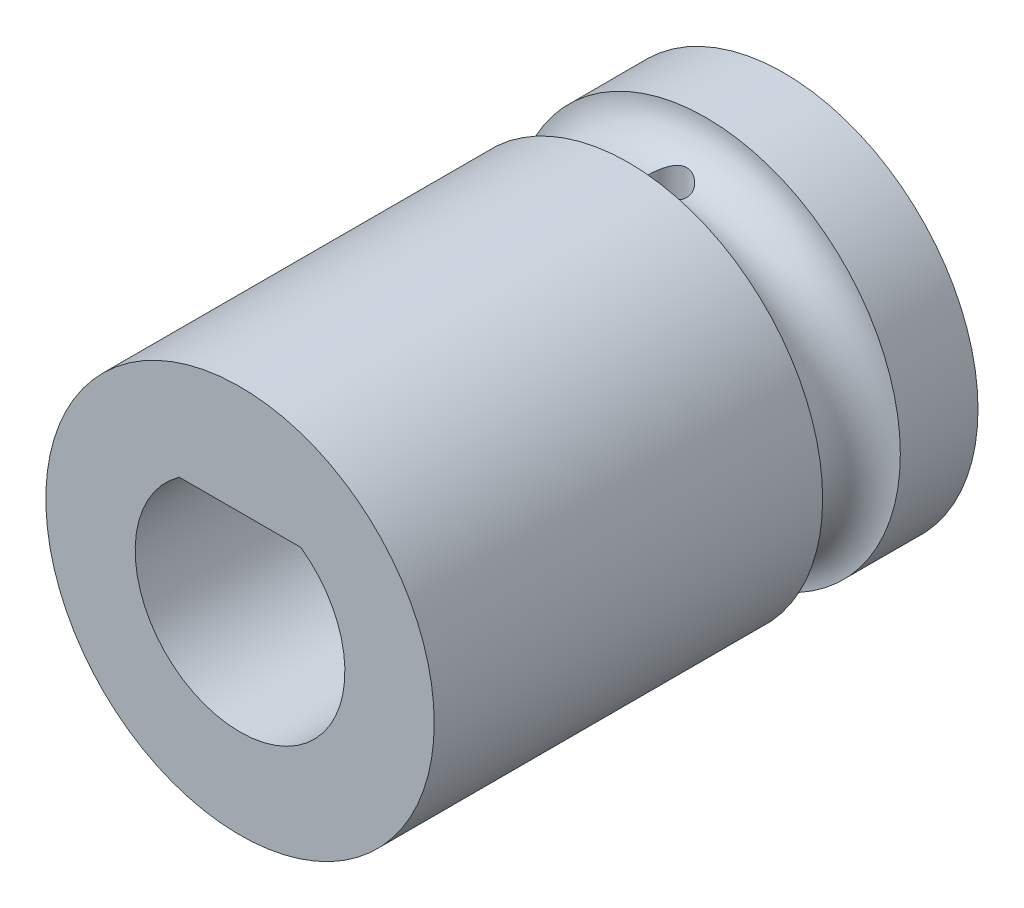
from build123d import *

# Parameters (mm, degrees)
SKETCH1_R                = 5
BOSS_EXTRUDE1_DEPTH      = 11
BOSS_EXTRUDE1_DEPTH_BACK = 3
SKETCH3_R                = 0.5
CUT_EXTRUDE1_DEPTH       = 11
CUT_EXTRUDE2_DEPTH       = 3


with BuildPart() as part:
    # Sketch1 → Boss-Extrude1 (new body, two sides)
    with BuildSketch(Plane.XY) as boss_extrude1_sk:
        Circle(SKETCH1_R)
        with BuildLine():
            Line((1.565247584, 2.2), (-1.565247584, 2.2))
            ThreePointArc((-1.565247584, 2.2), (0, -2.7), (1.565247584, 2.2))
        make_face(mode=Mode.SUBTRACT)
    extrude(amount=BOSS_EXTRUDE1_DEPTH)
    extrude(boss_extrude1_sk.sketch, amount=-BOSS_EXTRUDE1_DEPTH_BACK)

    # Sketch2 → Cut-Revolve1 (revolve, cut)
    with BuildSketch(Plane(origin=(0, 0, 0), x_dir=(0, 0, -1), z_dir=(1, 0, 0))):
        with BuildLine():
            Line((1, 5), (-1, 5))
            ThreePointArc((-1, 5), (0, 4), (1, 5))
        make_face()
    revolve(axis=Axis((0, 0, 0), (0, 0, 1)), mode=Mode.SUBTRACT)

    # Sketch3 → Cut-Extrude1 (cut)
    with BuildSketch(Plane(origin=(0, 0, 0), x_dir=(1, 0, 0), z_dir=(0, 1, 0))):
        Circle(SKETCH3_R)
    extrude(amount=CUT_EXTRUDE1_DEPTH, mode=Mode.SUBTRACT)

    # Sketch4 → Cut-Extrude2 (cut)
    with BuildSketch(Plane(origin=(0, 0, -3), x_dir=(-1, 0, 0), z_dir=(0, 0, -1))):
        with BuildLine():
            Line((-0.5, 2.2), (0.5, 2.2))
            ThreePointArc((0.5, 2.2), (0, 2.7), (-0.5, 2.2))
        make_face()
    extrude(amount=-CUT_EXTRUDE2_DEPTH, mode=Mode.SUBTRACT)


solid = part.part
